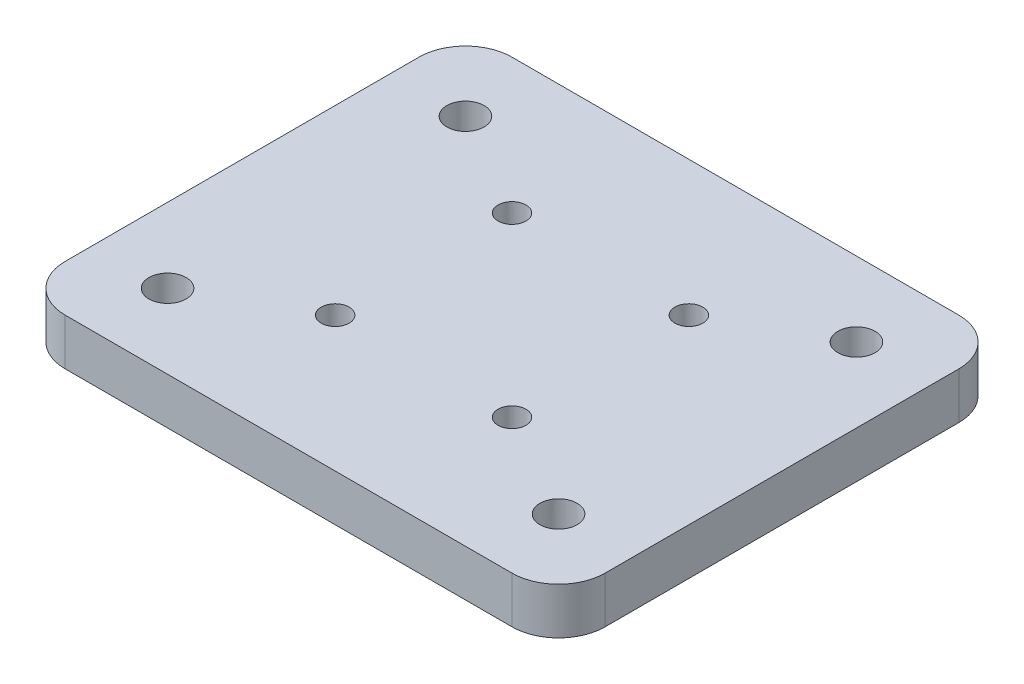
from build123d import *

# Parameters (mm, degrees)
SKETCH1_W           = 58
SKETCH1_H           = 48
BOSS_EXTRUDE1_DEPTH = 5
SKETCH2_R           = 2
SKETCH2_R_2         = 1.5
CUT_EXTRUDE1_DEPTH  = 5
FILLET1_R           = 5
FILLET2_R           = 5
FILLET3_R           = 5
FILLET4_R           = 5


with BuildPart() as part:
    # Sketch1 → Boss-Extrude1 (new body)
    with BuildSketch(Plane(origin=(0, 0, 0), x_dir=(1, 0, 0), z_dir=(0, 1, 0))):
        Rectangle(SKETCH1_W, SKETCH1_H)
    extrude(amount=BOSS_EXTRUDE1_DEPTH)

    # Sketch2 → Cut-Extrude1 (cut)
    with BuildSketch(Plane(origin=(0, 5, 0), x_dir=(1, 0, 0), z_dir=(0, 1, 0))):
        with Locations((21, -16)):
            Circle(SKETCH2_R)
        with Locations((-21, -16)):
            Circle(SKETCH2_R)
        with Locations((-21, 16)):
            Circle(SKETCH2_R)
        with Locations((21, 16)):
            Circle(SKETCH2_R)
        with Locations((9.5, -9.5)):
            Circle(SKETCH2_R_2)
        with Locations((-9.5, -9.5)):
            Circle(SKETCH2_R_2)
        with Locations((9.5, 9.5)):
            Circle(SKETCH2_R_2)
        with Locations((-9.5, 9.5)):
            Circle(SKETCH2_R_2)
    extrude(amount=-CUT_EXTRUDE1_DEPTH, mode=Mode.SUBTRACT)

    # Fillet1
    fillet1_edges = [part.edges().sort_by_distance(p)[0] for p in [
        (-29, 2.5, 24),
    ]]
    fillet(fillet1_edges, radius=FILLET1_R)

    # Fillet2
    fillet2_edges = [part.edges().sort_by_distance(p)[0] for p in [
        (29, 2.5, 24),
    ]]
    fillet(fillet2_edges, radius=FILLET2_R)

    # Fillet3
    fillet3_edges = [part.edges().sort_by_distance(p)[0] for p in [
        (29, 2.5, -24),
    ]]
    fillet(fillet3_edges, radius=FILLET3_R)

    # Fillet4
    fillet4_edges = [part.edges().sort_by_distance(p)[0] for p in [
        (-29, 2.5, -24),
    ]]
    fillet(fillet4_edges, radius=FILLET4_R)


solid = part.part
